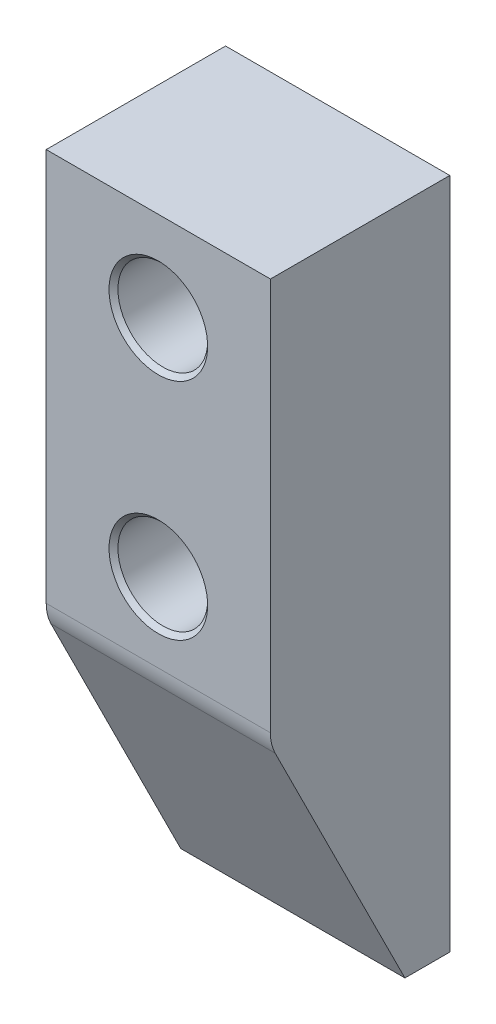
from build123d import *

# Parameters (mm, degrees)
SKETCH_1_W          = 50
SKETCH_1_H          = 150
EXTRUDE_1_DEPTH     = 40
CHAMFER_1_SIZE      = 30
CHAMFER_1_SIZE2     = 60
FILLET_1_R          = 10
SKETCH_2_R          = 10
CUT_EXTRUDE_1_DEPTH = 15
CHAMFER_2_SIZE      = 1
SKETCH_3_R          = 5
CUT_EXTRUDE_2_DEPTH = 26


with BuildPart() as part:
    # 草图1 → 凸台-拉伸1 (new body)
    with BuildSketch(Plane.XY):
        with Locations((25, 75)):
            Rectangle(SKETCH_1_W, SKETCH_1_H)
    extrude(amount=EXTRUDE_1_DEPTH)

    # 倒角1
    chamfer_1_edges = [part.edges().sort_by_distance(p)[0] for p in [
        (25, 0, 40),
    ]]
    chamfer_1_side = [part.faces().sort_by_distance(p)[0] for p in [
        (25, 0, 20),
    ]]
    chamfer(chamfer_1_edges, length=CHAMFER_1_SIZE, length2=CHAMFER_1_SIZE2, reference=chamfer_1_side[0])

    # 圆角1
    fillet_1_edges = [part.edges().sort_by_distance(p)[0] for p in [
        (25, 60, 40),
    ]]
    fillet(fillet_1_edges, radius=FILLET_1_R)

    # 草图2 → 切除-拉伸1 (cut)
    with BuildSketch(Plane.XY.offset(40)):
        with Locations((25, 130)):
            Circle(SKETCH_2_R)
        with Locations((25, 80)):
            Circle(SKETCH_2_R)
    extrude(amount=-CUT_EXTRUDE_1_DEPTH, mode=Mode.SUBTRACT)

    # 倒角2
    chamfer_2_edges = [part.edges().sort_by_distance(p)[0] for p in [
        (15, 130, 40),
        (15, 80, 40),
    ]]
    chamfer(chamfer_2_edges, length=CHAMFER_2_SIZE)

    # 草图3 → 切除-拉伸2 (cut, through all)
    with BuildSketch(Plane.XY.offset(25)):
        with Locations((25, 130)):
            Circle(SKETCH_3_R)
        with Locations((25, 80)):
            Circle(SKETCH_3_R)
    extrude(amount=-CUT_EXTRUDE_2_DEPTH, mode=Mode.SUBTRACT)


solid = part.part
